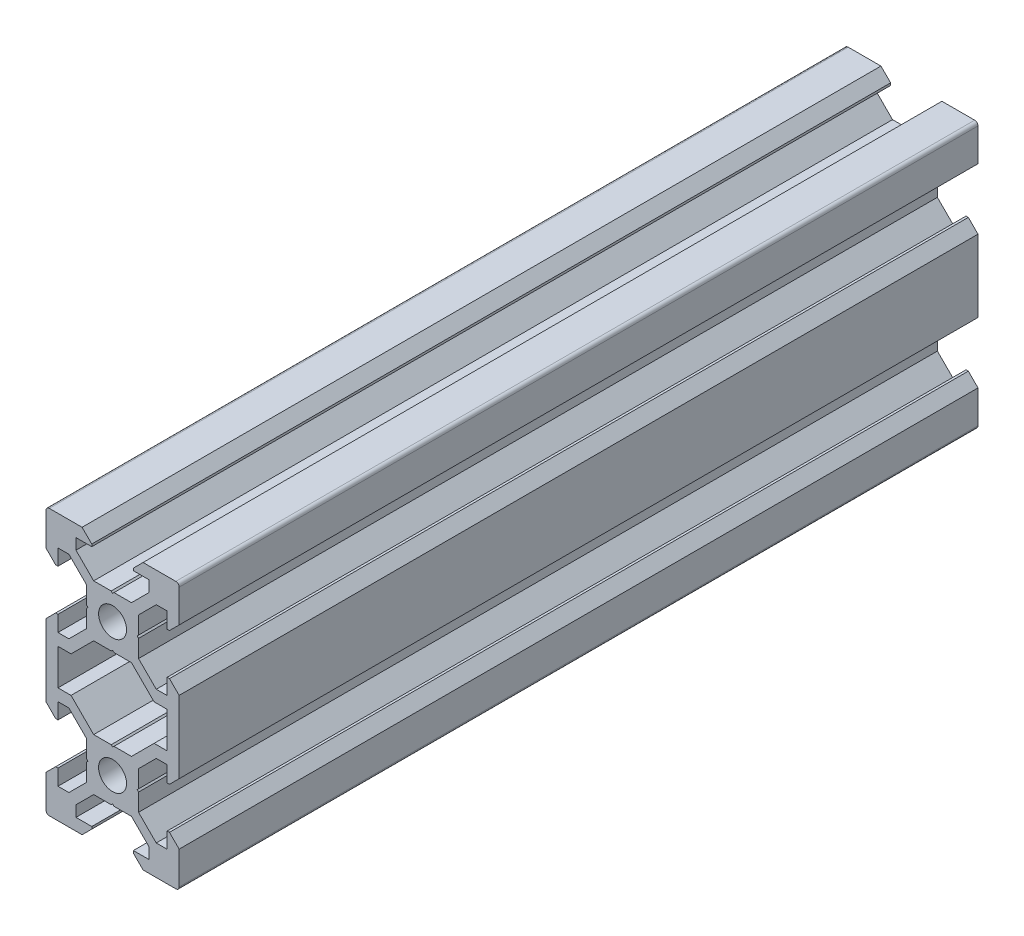
from build123d import *
from build123d.topology import SkipClean

# Parameters (mm, degrees)
BOSS_EXTRU_1_DEPTH     = 120
SYM_TRIE6_COPY_1_DEPTH = 120


with BuildPart() as part:
    # Esquisse1 → Boss.-Extru.1 (new body)
    with BuildSketch(Plane.XY):
        with BuildLine():
            Line((-9.5, 10), (-4.58, 10))
            Line((-4.58, 10), (-3.125, 8.545))
            Line((-3.125, 8.545), (-3.125, 8.2))
            Line((-3.125, 8.2), (-5.5, 8.2))
            Line((-5.5, 8.2), (-5.5, 6.560660172))
            Line((-5.5, 6.560660172), (-2.839339828, 3.9))
            Line((-2.839339828, 3.9), (-0.21, 3.9))
            Line((-0.21, 3.9), (0, 3.69))
            Line((0, 3.69), (0, 2.1))
            ThreePointArc((0, 2.1), (-2.1, 0), (0, -2.1))
            Line((0, -2.1), (0, -3.69))
            Line((0, -3.69), (-0.21, -3.9))
            Line((-0.21, -3.9), (-2.839339828, -3.9))
            Line((-2.839339828, -3.9), (-6.239339828, -7.3))
            Line((-6.239339828, -7.3), (-8.2, -7.3))
            Line((-8.2, -7.3), (-8.2, -10))
            Line((-8.2, -10), (-10, -10))
            Line((-10, -10), (-10, -4.58))
            Line((-10, -4.58), (-8.545, -3.125))
            Line((-8.545, -3.125), (-8.2, -3.125))
            Line((-8.2, -3.125), (-8.2, -5.5))
            Line((-8.2, -5.5), (-6.560660172, -5.5))
            Line((-6.560660172, -5.5), (-3.9, -2.839339828))
            Line((-3.9, -2.839339828), (-3.9, -0.21))
            Line((-3.9, -0.21), (-3.69, 0))
            Line((-3.69, 0), (-3.9, 0.21))
            Line((-3.9, 0.21), (-3.9, 2.839339828))
            Line((-3.9, 2.839339828), (-6.560660172, 5.5))
            Line((-6.560660172, 5.5), (-8.2, 5.5))
            Line((-8.2, 5.5), (-8.2, 3.125))
            Line((-8.2, 3.125), (-8.545, 3.125))
            Line((-8.545, 3.125), (-10, 4.58))
            Line((-10, 4.58), (-10, 9.5))
            ThreePointArc((-10, 9.5), (-9.853553391, 9.853553391), (-9.5, 10))
        make_face()
    boss_extru_1 = extrude(amount=BOSS_EXTRU_1_DEPTH)

    # Symétrie1: Boss.-Extru.1 across plane
    add(boss_extru_1.mirror(Plane(origin=(0, 3.69, 120), x_dir=(0, 0, 1), z_dir=(-1, 0, 0))))

    # Symétrie6: Boss.-Extru.1 across plane
    add(boss_extru_1.mirror(Plane(origin=(-8.2, -10, 120), x_dir=(0, 0, 1), z_dir=(0, 1, 0))))

    # Symétrie6 copy 1 sketch → Symétrie6 copy 1 (add)
    with SkipClean():  # the faces are left unmerged after this step: merging them gives an invalid solid
        with BuildSketch(Plane(origin=(0, -20, 0), x_dir=(-1, 0, 0), z_dir=(0, 0, 1))):
            with BuildLine():
                Line((-9.5, 10), (-4.58, 10))
                Line((-4.58, 10), (-3.125, 8.545))
                Line((-3.125, 8.545), (-3.125, 8.2))
                Line((-3.125, 8.2), (-5.5, 8.2))
                Line((-5.5, 8.2), (-5.5, 6.560660172))
                Line((-5.5, 6.560660172), (-2.839339828, 3.9))
                Line((-2.839339828, 3.9), (-0.21, 3.9))
                Line((-0.21, 3.9), (0, 3.69))
                Line((0, 3.69), (0, 2.1))
                ThreePointArc((0, 2.1), (-2.1, 0), (0, -2.1))
                Line((0, -2.1), (0, -3.69))
                Line((0, -3.69), (-0.21, -3.9))
                Line((-0.21, -3.9), (-2.839339828, -3.9))
                Line((-2.839339828, -3.9), (-6.239339828, -7.3))
                Line((-6.239339828, -7.3), (-8.2, -7.3))
                Line((-8.2, -7.3), (-8.2, -10))
                Line((-8.2, -10), (-10, -10))
                Line((-10, -10), (-10, -4.58))
                Line((-10, -4.58), (-8.545, -3.125))
                Line((-8.545, -3.125), (-8.2, -3.125))
                Line((-8.2, -3.125), (-8.2, -5.5))
                Line((-8.2, -5.5), (-6.560660172, -5.5))
                Line((-6.560660172, -5.5), (-3.9, -2.839339828))
                Line((-3.9, -2.839339828), (-3.9, -0.21))
                Line((-3.9, -0.21), (-3.69, 0))
                Line((-3.69, 0), (-3.9, 0.21))
                Line((-3.9, 0.21), (-3.9, 2.839339828))
                Line((-3.9, 2.839339828), (-6.560660172, 5.5))
                Line((-6.560660172, 5.5), (-8.2, 5.5))
                Line((-8.2, 5.5), (-8.2, 3.125))
                Line((-8.2, 3.125), (-8.545, 3.125))
                Line((-8.545, 3.125), (-10, 4.58))
                Line((-10, 4.58), (-10, 9.5))
                ThreePointArc((-10, 9.5), (-9.853553391, 9.853553391), (-9.5, 10))
            make_face()
        extrude(amount=SYM_TRIE6_COPY_1_DEPTH)


solid = part.part
